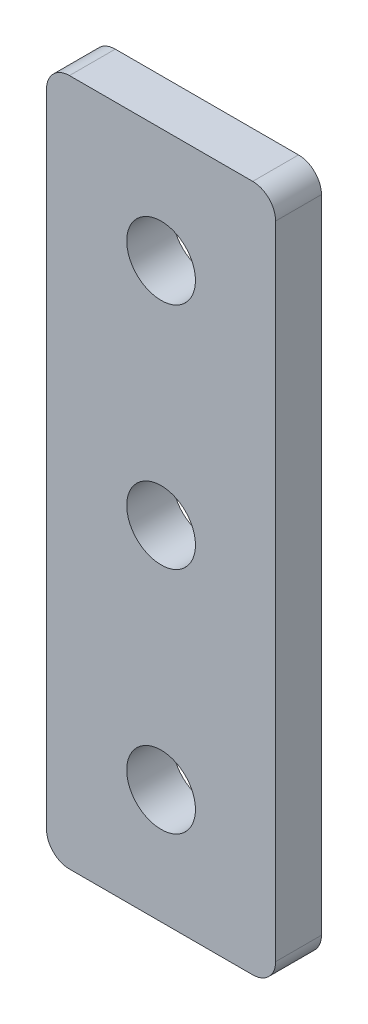
from build123d import *

# Parameters (mm, degrees)
SKETCH_1_W      = 10
SKETCH_1_H      = 30
SKETCH_1_R      = 1.5
EXTRUDE_1_DEPTH = 2
FILLET_1_R      = 1


with BuildPart() as part:
    # 草图1 → 凸台-拉伸1 (new body)
    with BuildSketch(Plane.XY):
        with Locations((1.642083631, -16.90903272)):
            Rectangle(SKETCH_1_W, SKETCH_1_H)
        with Locations((1.642083631, -6.90903272)):
            Circle(SKETCH_1_R, mode=Mode.SUBTRACT)
        with Locations((1.642083631, -16.90903272)):
            Circle(SKETCH_1_R, mode=Mode.SUBTRACT)
        with Locations((1.642083631, -26.90903272)):
            Circle(SKETCH_1_R, mode=Mode.SUBTRACT)
    extrude(amount=EXTRUDE_1_DEPTH)

    # 圆角1
    fillet_1_edges = [part.edges().sort_by_distance(p)[0] for p in [
        (-3.357916369, -1.90903272, 1),
        (6.642083631, -1.90903272, 1),
        (6.642083631, -31.90903272, 1),
        (-3.357916369, -31.90903272, 1),
    ]]
    fillet(fillet_1_edges, radius=FILLET_1_R)


solid = part.part
